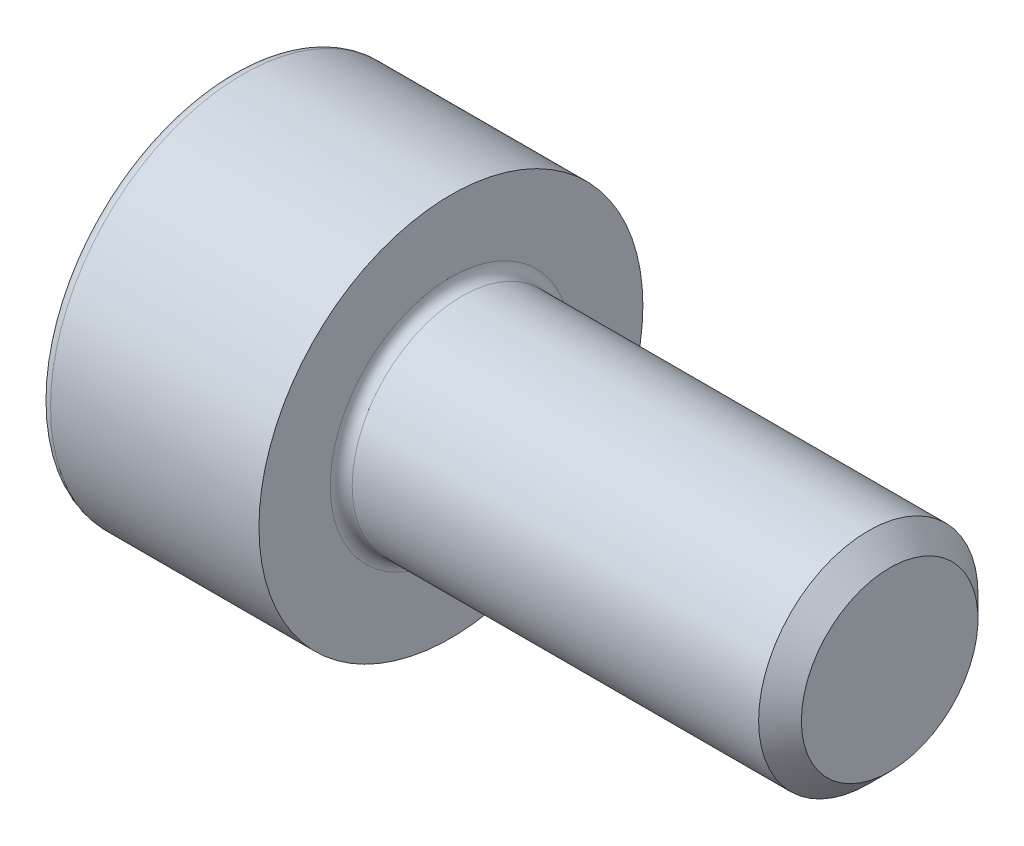
from build123d import *

# Parameters (mm, degrees)
FILLET1_R   = 0.2
FILLET2_R   = 0.2
HEX_2_DEPTH = 2


with BuildPart() as part:
    # BodySke → Base-Revolve (revolve)
    with BuildSketch(Plane.XY, mode=Mode.PRIVATE) as base_revolve_sk:
        Polygon((0, 0), (0, 3.5), (4, 3.5), (4, 2), (11.61, 2), (12, 1.61), (12, 0), align=None)
    revolve(base_revolve_sk.sketch.rotate(Axis((-31.75, 0, 0), (1, 0, 0)), 90), axis=Axis((-31.75, 0, 0), (1, 0, 0)))  # turned: the seam where the file's is

    # Fillet1
    fillet1_edges = [part.edges().sort_by_distance(p)[0] for p in [
        (4, 0, -2),
    ]]
    fillet(fillet1_edges, radius=FILLET1_R)

    # Fillet2
    fillet2_edges = [part.edges().sort_by_distance(p)[0] for p in [
        (0, 0, -3.5),
    ]]
    fillet(fillet2_edges, radius=FILLET2_R)

    # Sketch2 → Hex-PreBroach (revolve, cut)
    with BuildSketch(Plane.XY, mode=Mode.PRIVATE) as hex_prebroach_sk:
        Polygon((0, 1.5355), (2, 1.5355), (2.886521338, 0), (0, 0), align=None)
    revolve(hex_prebroach_sk.sketch.rotate(Axis((0, 0, 0), (1, 0, 0)), 90), axis=Axis((0, 0, 0), (1, 0, 0)), mode=Mode.SUBTRACT)  # turned: the seam where the file's is

    # Sketch3 → Hex 2 (cut)
    with BuildSketch(Plane(origin=(0, 0, 0), x_dir=(0, 0.5, 0.866025404), z_dir=(-1, 0, 0))):
        Polygon((0.886521338, 1.5355), (-0.886521338, 1.5355), (-1.773042677, 0), (-0.886521338, -1.5355), (0.886521338, -1.5355), (1.773042677, 0), align=None)
    extrude(amount=-HEX_2_DEPTH, mode=Mode.SUBTRACT)


solid = part.part
